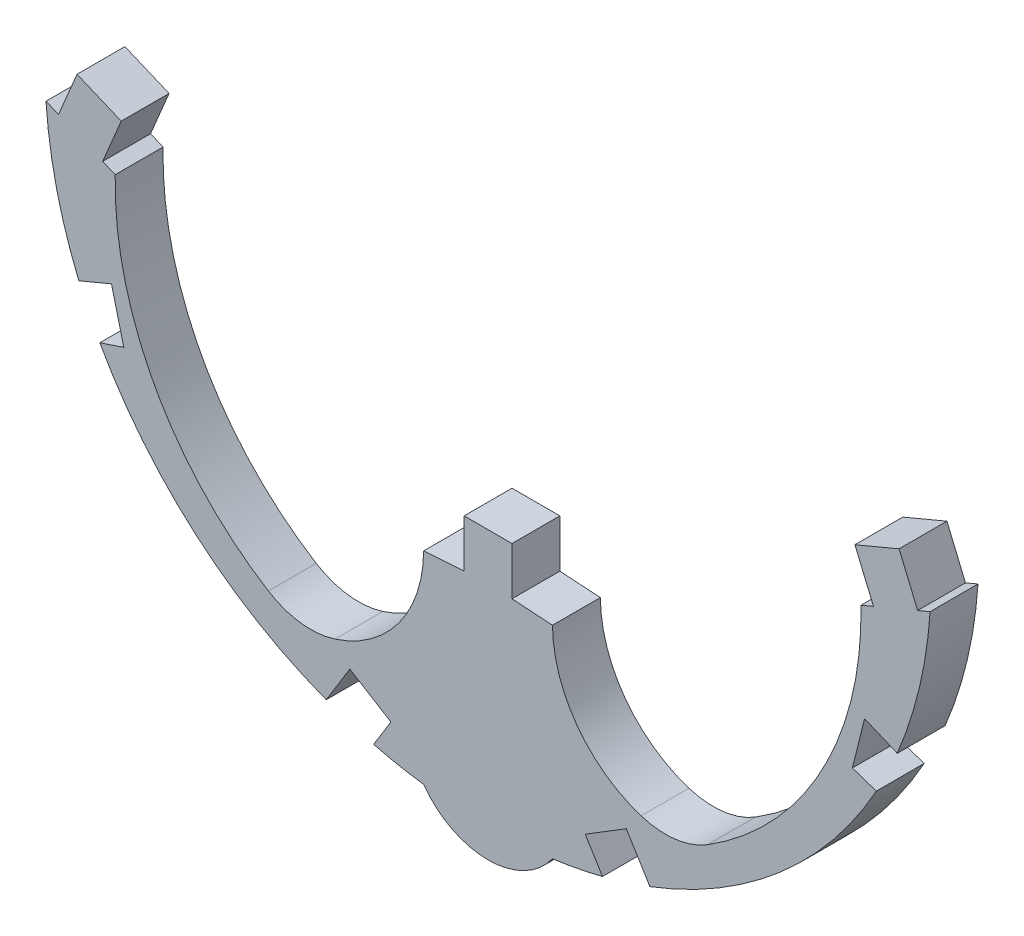
from build123d import *

# Parameters (mm, degrees)
BOSS_EXTRUDE1_DEPTH = 1.524


with BuildPart() as part:
    # Sketch1 → Boss-Extrude1 (new body)
    with BuildSketch(Plane.XY):
        with BuildLine():
            Line((108.324157749, 0), (107.562157749, 0))
            Line((107.562157749, 0), (106.800157749, 0))
            Line((106.800157749, 0), (106.800157749, -1.524))
            Line((106.800157749, -1.524), (105.512237426, -1.608526345))
            ThreePointArc((105.512237426, -1.608526345), (104.724998688, -3.987284572), (102.691709144, -5.451514459))
            ThreePointArc((102.691709144, -5.451514459), (101.601320714, -5.553518588), (100.569337767, -5.186963043))
            ThreePointArc((100.569337767, -5.186963043), (96.93524901, -1.312980348), (95.693576873, 3.851571261))
            Line((95.693576873, 3.851571261), (95.294914698, 4.01890801))
            Line((95.294914698, 4.01890801), (95.88475327, 5.424136269))
            Line((95.88475327, 5.424136269), (94.479525012, 6.013974841))
            Line((94.479525012, 6.013974841), (93.889686439, 4.608746583))
            Line((93.889686439, 4.608746583), (93.491024264, 4.776083332))
            ThreePointArc((93.491024264, 4.776083332), (93.831172669, 2.518689403), (94.536866699, 0.347624174))
            Line((94.536866699, 0.347624174), (95.57577022, 0.782745178))
            Line((95.57577022, 0.782745178), (95.966908102, -0.770781875))
            Line((95.966908102, -0.770781875), (95.203689029, -1.026803893))
            ThreePointArc((95.203689029, -1.026803893), (98.254836233, -4.783797634), (102.410778326, -7.264250525))
            Line((102.410778326, -7.264250525), (103.161744097, -6.043467632))
            Line((103.161744097, -6.043467632), (104.468983276, -6.847617069))
            Line((104.468983276, -6.847617069), (103.919709272, -7.740526353))
            ThreePointArc((103.919709272, -7.740526353), (104.711489507, -7.917129066), (105.512237426, -8.047156867))
            ThreePointArc((105.512237426, -8.047156867), (107.562157749, -9.102849891), (109.612078072, -8.047156867))
            ThreePointArc((109.612078072, -8.047156867), (110.412825991, -7.917129066), (111.204606226, -7.740526353))
            Line((111.204606226, -7.740526353), (110.655332222, -6.847617069))
            Line((110.655332222, -6.847617069), (111.962571401, -6.043467632))
            Line((111.962571401, -6.043467632), (112.713537171, -7.264250525))
            ThreePointArc((112.713537171, -7.264250525), (116.869479265, -4.783797634), (119.920626468, -1.026803893))
            Line((119.920626468, -1.026803893), (119.157407395, -0.770781875))
            Line((119.157407395, -0.770781875), (119.548545278, 0.782745178))
            Line((119.548545278, 0.782745178), (120.587448799, 0.347624174))
            ThreePointArc((120.587448799, 0.347624174), (121.293142829, 2.518689403), (121.633291234, 4.776083332))
            Line((121.633291234, 4.776083332), (121.234629058, 4.608746583))
            Line((121.234629058, 4.608746583), (120.644790486, 6.013974841))
            Line((120.644790486, 6.013974841), (119.239562227, 5.424136269))
            Line((119.239562227, 5.424136269), (119.8294008, 4.01890801))
            Line((119.8294008, 4.01890801), (119.430738625, 3.851571261))
            ThreePointArc((119.430738625, 3.851571261), (118.189066488, -1.312980348), (114.55497773, -5.186963043))
            ThreePointArc((114.55497773, -5.186963043), (113.522994784, -5.553518588), (112.432606354, -5.451514459))
            ThreePointArc((112.432606354, -5.451514459), (110.399316809, -3.987284572), (109.612078072, -1.608526345))
            Line((109.612078072, -1.608526345), (108.324157749, -1.524))
            Line((108.324157749, -1.524), (108.324157749, 0))
        make_face()
    extrude(amount=BOSS_EXTRUDE1_DEPTH)


solid = part.part
